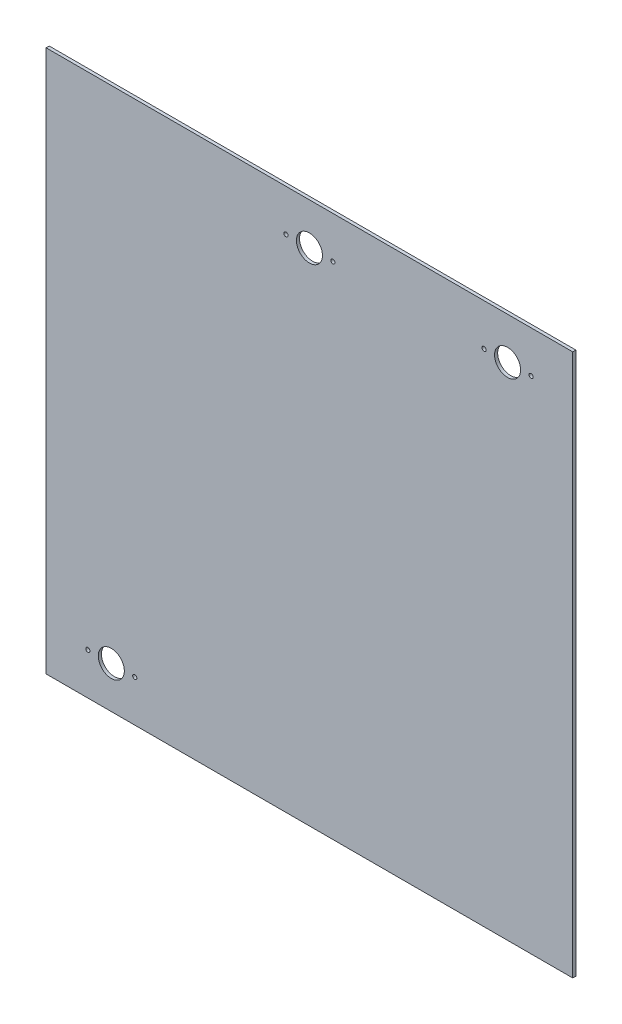
from build123d import *

# Parameters (mm, degrees)
SKICA1_W                = 505
SKICA1_H                = 520
SKICA1_R                = 2
SKICA1_R_2              = 12.5
P_IDAT_VYSUNUT_M1_DEPTH = 3


with BuildPart() as part:
    # Skica1 → Přidat vysunutím1 (new body)
    with BuildSketch(Plane.XY):
        Rectangle(SKICA1_W, SKICA1_H)
        with Locations((-212.5, -220)):
            Circle(SKICA1_R, mode=Mode.SUBTRACT)
        with Locations((-190, -220)):
            Circle(SKICA1_R_2, mode=Mode.SUBTRACT)
        with Locations((-167.5, -220)):
            Circle(SKICA1_R, mode=Mode.SUBTRACT)
        with Locations((-22.5, 220)):
            Circle(SKICA1_R, mode=Mode.SUBTRACT)
        with Locations((0, 220)):
            Circle(SKICA1_R_2, mode=Mode.SUBTRACT)
        with Locations((22.5, 220)):
            Circle(SKICA1_R, mode=Mode.SUBTRACT)
        with Locations((167.5, 220)):
            Circle(SKICA1_R, mode=Mode.SUBTRACT)
        with Locations((190, 220)):
            Circle(SKICA1_R_2, mode=Mode.SUBTRACT)
        with Locations((212.5, 220)):
            Circle(SKICA1_R, mode=Mode.SUBTRACT)
    extrude(amount=P_IDAT_VYSUNUT_M1_DEPTH)


solid = part.part
